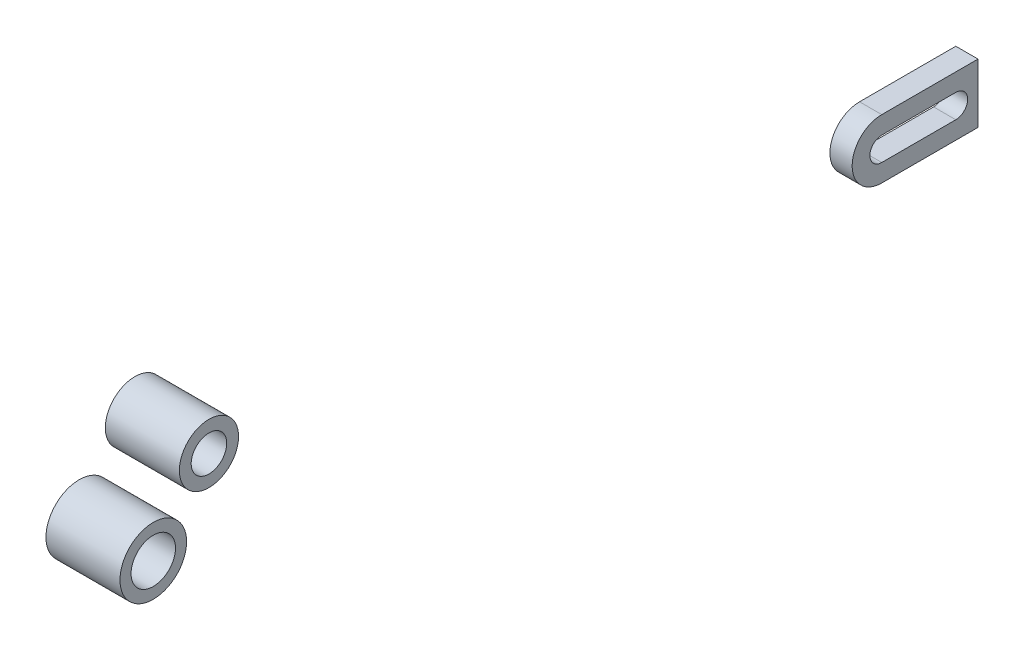
from build123d import *

# Parameters (mm, degrees)
SZKIC_INSERT_RAMA_R      = 22.5
SZKIC_INSERT_RAMA_R_2    = 15
RAMA_DEPTH               = 50
SZKIC_INSERT_LINKAGE_R   = 20
SZKIC_INSERT_LINKAGE_R_2 = 12
LINKAGE_DEPTH            = 25
TYLNE_KO_O_DEPTH         = 15


with BuildPart() as part:
    # Szkic - insert - rama → Rama (new body)
    with BuildSketch(Plane(origin=(135, 0, 0), x_dir=(0, 0, -1), z_dir=(1, 0, 0))):
        Circle(SZKIC_INSERT_RAMA_R)
        Circle(SZKIC_INSERT_RAMA_R_2, mode=Mode.SUBTRACT)
    extrude(amount=-RAMA_DEPTH)


with BuildPart() as body_2:
    # Szkic - insert - linkage → Linkage (new, symmetric)
    with BuildSketch(Plane(origin=(0, 0, 0), x_dir=(0, 0, -1), z_dir=(1, 0, 0))):
        with Locations((147.6, -66)):
            Circle(SZKIC_INSERT_LINKAGE_R)
        with Locations((147.6, -66)):
            Circle(SZKIC_INSERT_LINKAGE_R_2, mode=Mode.SUBTRACT)
    extrude(amount=LINKAGE_DEPTH, both=True)


with BuildPart() as body_3:
    # Szkic - insert - tylne koło → Tylne koło (new body)
    with BuildSketch(Plane(origin=(125, 0, 0), x_dir=(0, 0, -1), z_dir=(1, 0, 0))):
        with BuildLine():
            Line((487, 20), (552, 20))
            Line((552, 20), (552, -20))
            Line((552, -20), (487, -20))
            ThreePointArc((487, -20), (467, 0), (487, 20))
        make_face()
        with BuildLine():
            Line((537, 8), (487, 8))
            ThreePointArc((487, 8), (479, 0), (487, -8))
            Line((487, -8), (537, -8))
            ThreePointArc((537, -8), (545, 0), (537, 8))
        make_face(mode=Mode.SUBTRACT)
    extrude(amount=TYLNE_KO_O_DEPTH)


solid = Compound([part.part, body_2.part, body_3.part])
